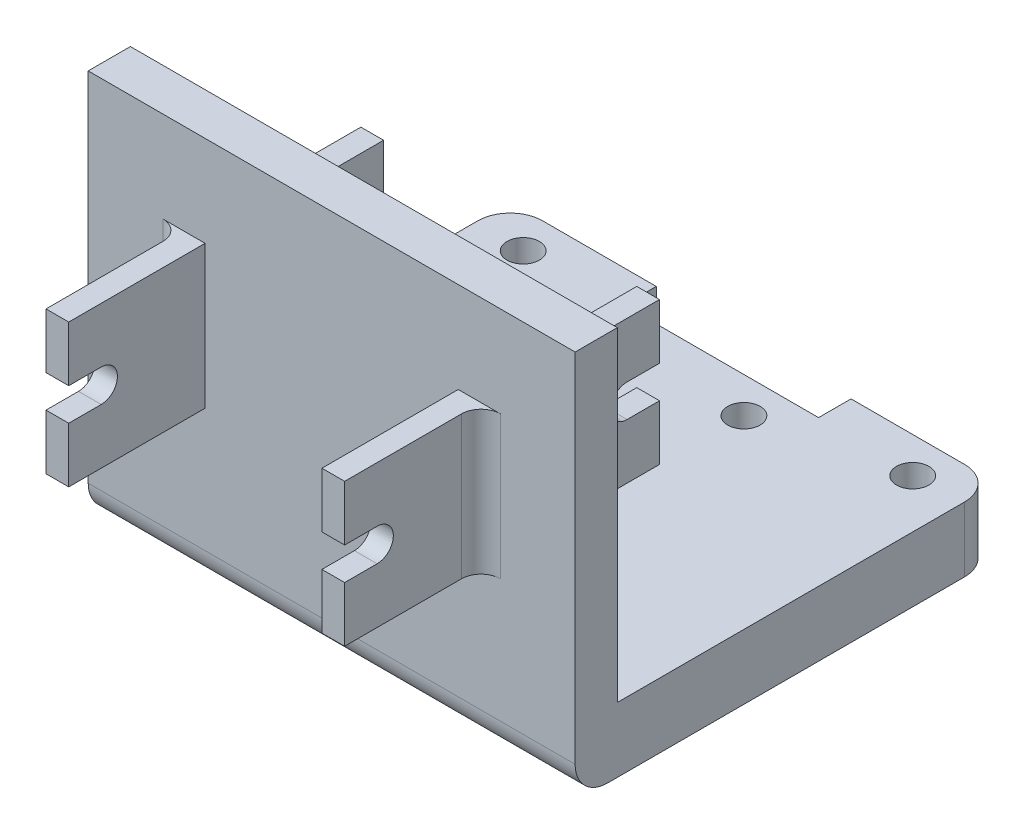
from build123d import *

# Parameters (mm, degrees)
SKETCH1_W           = 75
SKETCH1_H           = 55
SKETCH1_R           = 2.5
BOSS_EXTRUDE1_DEPTH = 10
SKETCH7_W           = 75
SKETCH7_H           = 10
BOSS_EXTRUDE2_DEPTH = 60
SKETCH9_W           = 75
SKETCH9_H           = 3.5
CUT_EXTRUDE5_DEPTH  = 50
FILLET3_R           = 5
FILLET4_R           = 5
SKETCH10_W          = 46
SKETCH10_H          = 30
BOSS_EXTRUDE3_DEPTH = 21
SKETCH11_W          = 36
SKETCH11_H          = 16
CUT_EXTRUDE6_DEPTH  = 51
SKETCH12_W          = 46
SKETCH12_H          = 30
BOSS_EXTRUDE4_DEPTH = 21
CUT_EXTRUDE7_REACH  = 52
SKETCH14_W          = 36
SKETCH14_H          = 16
SKETCH15_W          = 12
SKETCH15_H          = 5
BOSS_EXTRUDE5_DEPTH = 20
CUT_EXTRUDE9_DEPTH  = 30
SKETCH17_W          = 21
SKETCH17_H          = 4
CUT_EXTRUDE10_DEPTH = 61.5
FILLET5_R           = 3
SKETCH18_W          = 30
SKETCH18_H          = 30
CUT_EXTRUDE11_DEPTH = 5
SKETCH19_R          = 2.5
CUT_EXTRUDE12_DEPTH = 11


with BuildPart() as part:
    # Sketch1 → Boss-Extrude1 (new body)
    with BuildSketch(Plane(origin=(0, 0, 0), x_dir=(1, 0, 0), z_dir=(0, 1, 0))):
        Rectangle(SKETCH1_W, SKETCH1_H)
        with Locations((-30, 22)):
            Circle(SKETCH1_R, mode=Mode.SUBTRACT)
        with Locations((30, 22)):
            Circle(SKETCH1_R, mode=Mode.SUBTRACT)
        with Locations((0, -18)):
            Circle(SKETCH1_R, mode=Mode.SUBTRACT)
    extrude(amount=BOSS_EXTRUDE1_DEPTH)

    # Sketch7 → Boss-Extrude2 (add)
    with BuildSketch(Plane(origin=(0, 0, 0), x_dir=(1, 0, 0), z_dir=(0, 1, 0))):
        with Locations((0, -32.5)):
            Rectangle(SKETCH7_W, SKETCH7_H)
    extrude(amount=BOSS_EXTRUDE2_DEPTH)

    # Sketch9 → Cut-Extrude5 (cut)
    with BuildSketch(Plane(origin=(0, 60, 0), x_dir=(1, 0, 0), z_dir=(0, 1, 0))):
        with Locations((0, -29.25)):
            Rectangle(SKETCH9_W, SKETCH9_H)
    extrude(amount=-CUT_EXTRUDE5_DEPTH, mode=Mode.SUBTRACT)

    # Fillet3
    fillet3_edges = [part.edges().sort_by_distance(p)[0] for p in [
        (0, 0, 37.5),
    ]]
    fillet(fillet3_edges, radius=FILLET3_R)

    # Fillet4
    fillet4_edges = [part.edges().sort_by_distance(p)[0] for p in [
        (-37.5, 5, -27.5),
        (37.5, 5, -27.5),
    ]]
    fillet(fillet4_edges, radius=FILLET4_R)

    # Sketch10 → Boss-Extrude3 (add)
    with BuildSketch(Plane.XY.offset(37.5)):
        with Locations((0, 35)):
            Rectangle(SKETCH10_W, SKETCH10_H)
    extrude(amount=BOSS_EXTRUDE3_DEPTH)

    # Sketch11 → Cut-Extrude6 (cut, through all)
    with BuildSketch(Plane(origin=(0, 50, 0), x_dir=(1, 0, 0), z_dir=(0, 1, 0))):
        with Locations((0, -45.5)):
            Rectangle(SKETCH11_W, SKETCH11_H)
    extrude(amount=-CUT_EXTRUDE6_DEPTH, mode=Mode.SUBTRACT)

    # Sketch12 → Boss-Extrude4 (add)
    with BuildSketch(Plane(origin=(0, 0, 31), x_dir=(-1, 0, 0), z_dir=(0, 0, -1))):
        with Locations((0, 35)):
            Rectangle(SKETCH12_W, SKETCH12_H)
    extrude(amount=BOSS_EXTRUDE4_DEPTH)

    # Sketch14 → Cut-Extrude7 (cut, up to next)
    with BuildSketch(Plane(origin=(0, 50, 0), x_dir=(1, 0, 0), z_dir=(0, 1, 0)), mode=Mode.PRIVATE) as cut_extrude7_sk1:
        with Locations((0, -23)):
            Rectangle(SKETCH14_W, SKETCH14_H)
    cut_extrude7_tool1 = extrude(cut_extrude7_sk1.sketch, amount=-CUT_EXTRUDE7_REACH, mode=Mode.PRIVATE) & part.part
    add(cut_extrude7_tool1.solids().sort_by_distance((0, 50, 23))[0], mode=Mode.SUBTRACT)

    # Sketch15 → Boss-Extrude5 (add)
    with BuildSketch(Plane.XZ):
        with Locations((-9, -25)):
            Rectangle(SKETCH15_W, SKETCH15_H)
        with Locations((9, -25)):
            Rectangle(SKETCH15_W, SKETCH15_H)
    extrude(amount=BOSS_EXTRUDE5_DEPTH)

    # Sketch16 → Cut-Extrude9 (cut)
    with BuildSketch(Plane(origin=(0, 50, 0), x_dir=(1, 0, 0), z_dir=(0, 1, 0))):
        Polygon((-19.5, -31), (-19.5, -12.885372955), (-19.5, -10), (19.5, -9.896863532), (19.5, -31), align=None)
        Polygon((19.5, -58.603136468), (19.5, -37.5), (-19.5, -37.5), (-19.5, -55.614627045), (-19.5, -58.5), align=None)
    extrude(amount=-CUT_EXTRUDE9_DEPTH, mode=Mode.SUBTRACT)

    # Sketch17 → Cut-Extrude10 (cut, through all)
    with BuildSketch(Plane.ZY.offset(23)):
        with Locations((48, 48)):
            Rectangle(SKETCH17_W, SKETCH17_H)
        with BuildLine():
            ThreePointArc((53.5, 32.5), (51, 35), (53.5, 37.5))
            Line((53.5, 37.5), (58.5, 37.5))
            Line((58.5, 37.5), (58.5, 32.5))
            Line((58.5, 32.5), (53.5, 32.5))
        make_face()
        with Locations((48, 22)):
            Rectangle(SKETCH17_W, SKETCH17_H)
        with Locations((20.5, 48)):
            Rectangle(SKETCH17_W, SKETCH17_H)
        with BuildLine():
            Line((10, 37.5), (10, 32.5))
            Line((10, 32.5), (15, 32.5))
            ThreePointArc((15, 32.5), (17.5, 35), (15, 37.5))
            Line((15, 37.5), (10, 37.5))
        make_face()
        with Locations((20.5, 22)):
            Rectangle(SKETCH17_W, SKETCH17_H)
    extrude(amount=-CUT_EXTRUDE10_DEPTH, mode=Mode.SUBTRACT)

    # Fillet5
    fillet5_edges = [part.edges().sort_by_distance(p)[0] for p in [
        (-23, 35, 31),
        (23, 35, 31),
        (23, 35, 37.5),
        (-23, 35, 37.5),
    ]]
    fillet(fillet5_edges, radius=FILLET5_R)

    # Sketch18 → Cut-Extrude11 (cut)
    with BuildSketch(Plane(origin=(0, 0, -27.5), x_dir=(-1, 0, 0), z_dir=(0, 0, -1))):
        with Locations((0, -5)):
            Rectangle(SKETCH18_W, SKETCH18_H)
    extrude(amount=-CUT_EXTRUDE11_DEPTH, mode=Mode.SUBTRACT)

    # Sketch19 → Cut-Extrude12 (cut, through all)
    with BuildSketch(Plane(origin=(0, 10, 0), x_dir=(1, 0, 0), z_dir=(0, 1, 0))):
        with Locations((-9, 17)):
            Circle(SKETCH19_R)
        with Locations((9, 17)):
            Circle(SKETCH19_R)
    extrude(amount=-CUT_EXTRUDE12_DEPTH, mode=Mode.SUBTRACT)


solid = part.part
